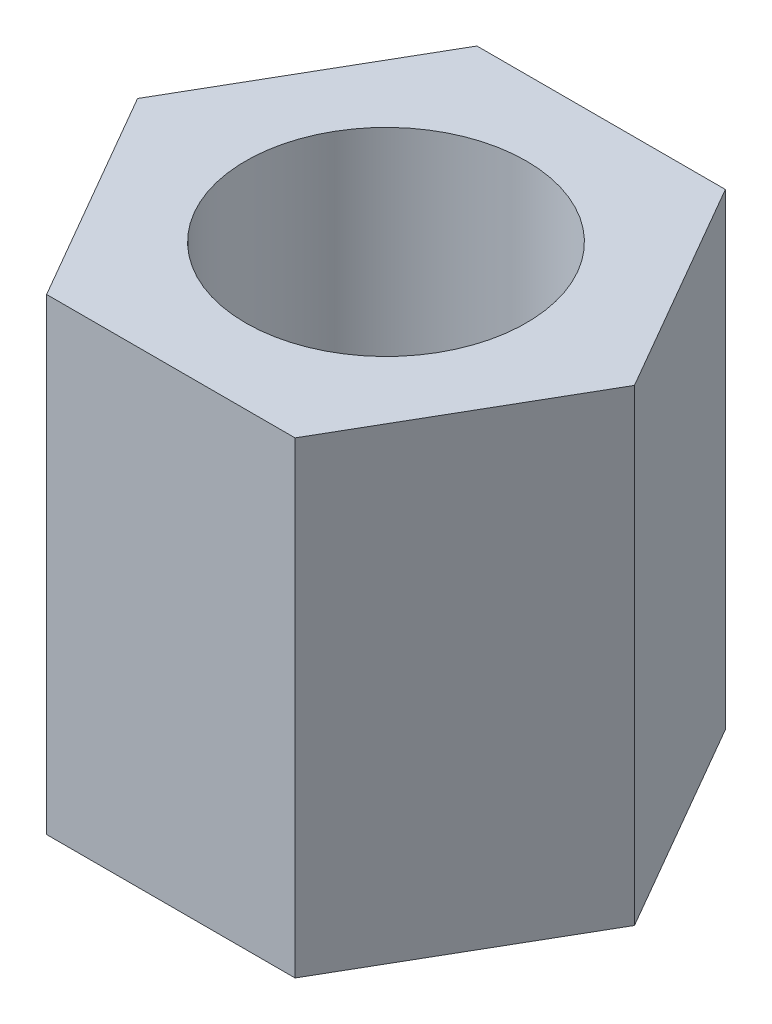
from build123d import *

# Parameters (mm, degrees)
SKETCH_1_R      = 1.5
EXTRUDE_2_DEPTH = 5


with BuildPart() as part:
    # 草图1 → 凸台-拉伸2 (new body)
    with BuildSketch(Plane(origin=(0, 0, 0), x_dir=(1, 0, 0), z_dir=(0, 1, 0))):
        Polygon((-1.327905619, 2.3), (-2.655811238, 0), (-1.327905619, -2.3), (1.327905619, -2.3), (2.655811238, 0), (1.327905619, 2.3), align=None)
        Circle(SKETCH_1_R, mode=Mode.SUBTRACT)
    extrude(amount=EXTRUDE_2_DEPTH)


solid = part.part
